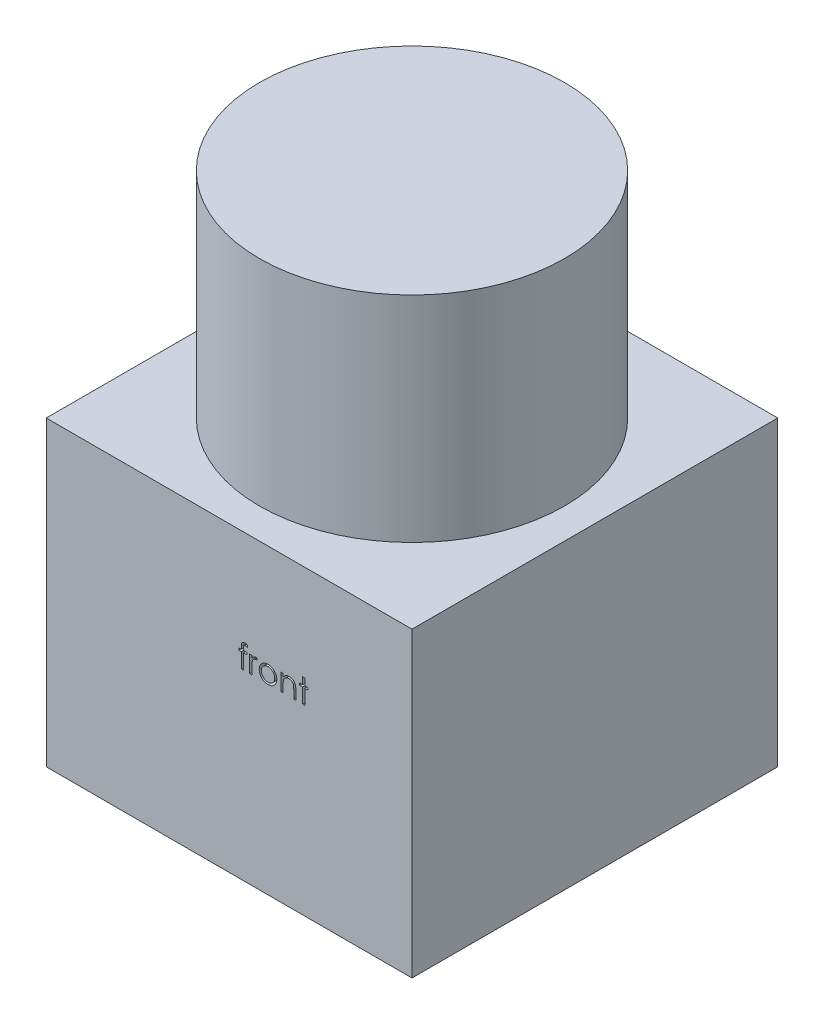
from build123d import *

# Parameters (mm, degrees)
SKETCH1_W           = 50
SKETCH1_H           = 41.3
BOSS_EXTRUDE1_DEPTH = 50
SKETCH2_R           = 20.85
BOSS_EXTRUDE2_DEPTH = 29.3
SKETCH3_R           = 1.7
CUT_EXTRUDE1_DEPTH  = 12.7
CUT_EXTRUDE2_DEPTH  = 2.54


with BuildPart() as part:
    # Sketch1 → Boss-Extrude1 (new body)
    with BuildSketch(Plane.XY):
        with Locations((25, 20.65)):
            Rectangle(SKETCH1_W, SKETCH1_H)
    extrude(amount=BOSS_EXTRUDE1_DEPTH)

    # Sketch2 → Boss-Extrude2 (add)
    with BuildSketch(Plane(origin=(0, 41.3, 0), x_dir=(1, 0, 0), z_dir=(0, 1, 0))):
        with Locations((25, -25)):
            Circle(SKETCH2_R)
    extrude(amount=BOSS_EXTRUDE2_DEPTH)

    # Sketch3 → Cut-Extrude1 (cut)
    with BuildSketch(Plane.XZ):
        with Locations((45.86404504, 45.86404504)):
            Circle(SKETCH3_R)
        with Locations((4.13595496, 4.13595496)):
            Circle(SKETCH3_R)
    extrude(amount=-CUT_EXTRUDE1_DEPTH, mode=Mode.SUBTRACT)

    # Sketch4 → Cut-Extrude2 (cut)
    with BuildSketch(Plane.XY.offset(50)):
        with BuildLine():
            Line((27.486215918, 28.180376343), (27.486215918, 27.883992128))
            add(Edge.make_bspline(
                [(27.486215918, 27.883992128), (27.459238597, 27.894833276), (27.408035081, 27.915410001), (27.332524168, 27.93778434), (27.263101583, 27.952240333), (27.218511983, 27.954268654), (27.197463915, 27.955226102)],
                knots=[0, 0, 0, 0, 8.7172e-05, 0.000165453, 0.000236054, 0.000299177, 0.000299177, 0.000299177, 0.000299177], degree=3))
            add(Edge.make_bspline(
                [(27.197463915, 27.955226102), (27.183245572, 27.954635244), (27.155723602, 27.953491539), (27.116169156, 27.947660174), (27.08052823, 27.935774062), (27.048863845, 27.920326075), (27.022601642, 27.90095478), (27.000116996, 27.881491791), (26.983818787, 27.859552377), (26.974969656, 27.839123148), (26.969572155, 27.820208318), (26.967948253, 27.800836948), (26.96397051, 27.777047955), (26.962861249, 27.747870868), (26.960332708, 27.714213409), (26.960556447, 27.675363296), (26.958484602, 27.631931888), (26.958794767, 27.601179247), (26.958957304, 27.585063843)],
                knots=[0, 0, 0, 0, 4.2689e-05, 8.2632e-05, 0.000119438, 0.000154993, 0.00018782, 0.000217084, 0.000243925, 0.000268981, 0.000283485, 0.000302734, 0.000327111, 0.000355796, 0.000390193, 0.00042836, 0.000472263, 0.000520601, 0.000520601, 0.000520601, 0.000520601], degree=3))
            Line((26.958957304, 27.585063843), (26.958957304, 27.263238923))
            Line((26.958957304, 27.263238923), (27.44551079, 27.263238923))
            Line((27.44551079, 27.263238923), (27.44551079, 26.978303025))
            Line((27.44551079, 26.978303025), (26.958321287, 26.978303025))
            Line((26.958321287, 26.978303025), (26.957049251, 24.943046615))
            Line((26.957049251, 24.943046615), (26.672113354, 24.943046615))
            Line((26.672113354, 24.943046615), (26.672113354, 26.978303025))
            Line((26.672113354, 26.978303025), (26.346472328, 26.978303025))
            Line((26.346472328, 26.978303025), (26.346472328, 27.263238923))
            Line((26.346472328, 27.263238923), (26.672113354, 27.263238923))
            Line((26.672113354, 27.263238923), (26.672113354, 27.6340372))
            add(Edge.make_bspline(
                [(26.672113354, 27.6340372), (26.672136227, 27.65460719), (26.672180107, 27.694068725), (26.675253371, 27.750864431), (26.677880203, 27.803318574), (26.683112266, 27.851023977), (26.689155385, 27.894427264), (26.697806044, 27.932883663), (26.705980645, 27.967429259), (26.720811153, 28.006529526), (26.742965595, 28.050843477), (26.77882513, 28.097673728), (26.821817359, 28.139678931), (26.873169195, 28.175064172), (26.930968288, 28.204469641), (26.995267642, 28.225553322), (27.065367286, 28.237473583), (27.113888062, 28.23924633), (27.138950293, 28.240162)],
                knots=[0, 0, 0, 0, 6.1697e-05, 0.00011836, 0.00017061, 0.000219214, 0.0002623, 0.000301968, 0.000337448, 0.000368639, 0.000427236, 0.000485368, 0.000544739, 0.000606848, 0.0006717, 0.000738675, 0.000809047, 0.000884229, 0.000884229, 0.000884229, 0.000884229], degree=3))
            add(Edge.make_bspline(
                [(27.138950293, 28.240162), (27.164419924, 28.239293519), (27.217892062, 28.237470189), (27.301527551, 28.226191312), (27.391875821, 28.206714021), (27.453866263, 28.189407654), (27.486215918, 28.180376343)],
                knots=[0, 0, 0, 0, 7.6417e-05, 0.000160434, 0.000252742, 0.000353487, 0.000353487, 0.000353487, 0.000353487], degree=3))
        make_face()
        with BuildLine():
            Line((27.811856944, 27.263238923), (28.096792841, 27.263238923))
            Line((28.096792841, 27.263238923), (28.096792841, 26.921697456))
            add(Edge.make_bspline(
                [(28.096792841, 26.921697456), (28.117828358, 26.953498101), (28.15805862, 27.014316586), (28.224926778, 27.094752309), (28.293419085, 27.161350244), (28.363863434, 27.214421293), (28.436777853, 27.254166051), (28.510562088, 27.283279018), (28.586376978, 27.300494154), (28.637323867, 27.302792545), (28.66284853, 27.303944051)],
                knots=[0, 0, 0, 0, 0.000114321, 0.000218637, 0.000313098, 0.00040036, 0.000482337, 0.000561472, 0.000637702, 0.000714238, 0.000714238, 0.000714238, 0.000714238], degree=3))
            add(Edge.make_bspline(
                [(28.66284853, 27.303944051), (28.682648126, 27.302864073), (28.723387082, 27.300641949), (28.785057003, 27.285029272), (28.84859642, 27.26010278), (28.889547014, 27.236662007), (28.910895405, 27.224441847)],
                knots=[0, 0, 0, 0, 5.9368e-05, 0.000122154, 0.000189829, 0.000263533, 0.000263533, 0.000263533, 0.000263533], degree=3))
            Line((28.910895405, 27.224441847), (28.754435069, 26.977667008))
            add(Edge.make_bspline(
                [(28.754435069, 26.977667008), (28.740729028, 26.983781392), (28.714712339, 26.995387664), (28.676653554, 27.00912363), (28.641564056, 27.01721164), (28.619208828, 27.018436933), (28.608787032, 27.019008154)],
                knots=[0, 0, 0, 0, 4.5014e-05, 8.5445e-05, 0.000121249, 0.000152517, 0.000152517, 0.000152517, 0.000152517], degree=3))
            add(Edge.make_bspline(
                [(28.608787032, 27.019008154), (28.585921831, 27.01748412), (28.539283448, 27.014375532), (28.470808224, 26.989938185), (28.404362545, 26.950454575), (28.351592537, 26.90666578), (28.310732779, 26.864440278), (28.281577003, 26.82756637), (28.254831939, 26.78622004), (28.229277525, 26.741108113), (28.20599453, 26.691460324), (28.184264223, 26.637772694), (28.16461654, 26.579983042), (28.153413104, 26.539721756), (28.147674251, 26.519098298)],
                knots=[0, 0, 0, 0, 6.8481e-05, 0.00013968, 0.000215495, 0.000299536, 0.000344518, 0.0003916, 0.000440288, 0.000492119, 0.000547026, 0.000604662, 0.000665806, 0.000730019, 0.000730019, 0.000730019, 0.000730019], degree=3))
            add(Edge.make_bspline(
                [(28.147674251, 26.519098298), (28.143381294, 26.500704005), (28.133872721, 26.459962043), (28.124627541, 26.391610167), (28.115493049, 26.310852991), (28.109055403, 26.217465724), (28.103088179, 26.111681579), (28.099722604, 25.9933394), (28.096907612, 25.862317717), (28.096832259, 25.770719553), (28.096792841, 25.722804227)],
                knots=[0, 0, 0, 0, 5.6638e-05, 0.000125448, 0.000206712, 0.000300468, 0.000406202, 0.000524563, 0.000655607, 0.000799348, 0.000799348, 0.000799348, 0.000799348], degree=3))
            Line((28.096792841, 25.722804227), (28.096792841, 24.943046615))
            Line((28.096792841, 24.943046615), (27.811856944, 24.943046615))
            Line((27.811856944, 24.943046615), (27.811856944, 27.263238923))
        make_face()
        with BuildLine():
            add(Edge.make_bspline(
                [(30.316494363, 27.303944051), (30.360029304, 27.30301705), (30.445390683, 27.301199427), (30.570402122, 27.281772994), (30.689732352, 27.252066456), (30.803838398, 27.210998682), (30.911258895, 27.155951484), (31.013558523, 27.090265913), (31.11045681, 27.012448846), (31.168534844, 26.952252598), (31.198014796, 26.921697456)],
                knots=[0, 0, 0, 0, 0.000130509, 0.000255897, 0.000378531, 0.000499054, 0.000618803, 0.000739829, 0.000863296, 0.000990571, 0.000990571, 0.000990571, 0.000990571], degree=3))
            add(Edge.make_bspline(
                [(31.198014796, 26.921697456), (31.223398426, 26.892474769), (31.273674442, 26.834594935), (31.338141201, 26.740745914), (31.393677902, 26.643554537), (31.438185017, 26.541730177), (31.47327786, 26.436161725), (31.49819317, 26.326486329), (31.513013104, 26.2129462), (31.51501151, 26.135835575), (31.51602361, 26.096782593)],
                knots=[0, 0, 0, 0, 0.000116043, 0.000229841, 0.000340916, 0.00045141, 0.000562633, 0.000674184, 0.000788337, 0.000905475, 0.000905475, 0.000905475, 0.000905475], degree=3))
            add(Edge.make_bspline(
                [(31.51602361, 26.096782593), (31.515133397, 26.057503255), (31.513374294, 25.979885451), (31.496734014, 25.865567883), (31.470852243, 25.754719723), (31.433811933, 25.64780505), (31.386315648, 25.544497057), (31.328357667, 25.445246966), (31.259531272, 25.349858959), (31.18151336, 25.259143006), (31.09528773, 25.175535083), (31.001746652, 25.102665867), (30.90272835, 25.040234912), (30.796916165, 24.989946164), (30.685276374, 24.950295222), (30.567568176, 24.922445921), (30.443974434, 24.905607822), (30.359585455, 24.903445581), (30.316494363, 24.902341487)],
                knots=[0, 0, 0, 0, 0.000117773, 0.000232725, 0.000345804, 0.000458844, 0.000571541, 0.000686407, 0.000803078, 0.000923941, 0.00104494, 0.001162753, 0.001279048, 0.001395399, 0.001513481, 0.001633808, 0.001757668, 0.001886907, 0.001886907, 0.001886907, 0.001886907], degree=3))
            add(Edge.make_bspline(
                [(30.316494363, 24.902341487), (30.273192154, 24.903449286), (30.188382588, 24.905618967), (30.06435259, 24.922380502), (29.946433436, 24.950282387), (29.834647493, 24.990076469), (29.728380382, 25.04023652), (29.628788345, 25.102477124), (29.535171279, 25.175556693), (29.448927407, 25.25913715), (29.370914387, 25.349860468), (29.302086729, 25.445246574), (29.244129076, 25.544497159), (29.196632706, 25.647805023), (29.159592418, 25.75471973), (29.133710641, 25.865567881), (29.117070362, 25.979885451), (29.115311259, 26.057503255), (29.114421046, 26.096782593)],
                knots=[0, 0, 0, 0, 0.000129874, 0.000254364, 0.000374691, 0.000492773, 0.000609698, 0.000726534, 0.000844346, 0.000965345, 0.001086209, 0.001202879, 0.001317745, 0.001430442, 0.001543482, 0.001656561, 0.001771513, 0.001889286, 0.001889286, 0.001889286, 0.001889286], degree=3))
            add(Edge.make_bspline(
                [(29.114421046, 26.096782593), (29.115440049, 26.135623316), (29.1174575, 26.212521274), (29.132262533, 26.325847965), (29.157080652, 26.435337739), (29.192215562, 26.540498707), (29.237132914, 26.641876852), (29.291889225, 26.739308378), (29.357013584, 26.832733025), (29.40708964, 26.890538055), (29.43242986, 26.919789404)],
                knots=[0, 0, 0, 0, 0.000116502, 0.000230655, 0.000342206, 0.000452826, 0.000562738, 0.000674367, 0.000787643, 0.000903686, 0.000903686, 0.000903686, 0.000903686], degree=3))
            add(Edge.make_bspline(
                [(29.43242986, 26.919789404), (29.461865368, 26.950609527), (29.519755473, 27.011222723), (29.617136105, 27.088812941), (29.719184071, 27.15586538), (29.827791682, 27.209818804), (29.941803989, 27.25230803), (30.061745731, 27.281849605), (30.187181377, 27.301129434), (30.272960462, 27.302996495), (30.316494363, 27.303944051)],
                knots=[0, 0, 0, 0, 0.000127724, 0.000251192, 0.000372563, 0.000493448, 0.000614191, 0.000736825, 0.000863471, 0.00099398, 0.00099398, 0.00099398, 0.00099398], degree=3))
        make_face()
        with BuildLine():
            add(Edge.make_bspline(
                [(30.315222328, 27.019008154), (30.284436067, 27.018133131), (30.223658286, 27.016405675), (30.134196234, 27.003266704), (30.048071951, 26.98245004), (29.965122043, 26.952873503), (29.885626236, 26.914683787), (29.809508421, 26.867776918), (29.736544708, 26.812774164), (29.668162407, 26.749761598), (29.605404167, 26.68092851), (29.550542003, 26.607587499), (29.503892085, 26.53092817), (29.465029941, 26.450870808), (29.436085563, 26.366604118), (29.415064321, 26.279082402), (29.401937746, 26.188127346), (29.400226531, 26.126295565), (29.399356944, 26.09487454)],
                knots=[0, 0, 0, 0, 9.233e-05, 0.000182276, 0.000270667, 0.000357773, 0.00044596, 0.000534752, 0.000625576, 0.000719657, 0.000813309, 0.000904642, 0.000993977, 0.001082163, 0.001171069, 0.001260696, 0.001351902, 0.001446138, 0.001446138, 0.001446138, 0.001446138], degree=3))
            add(Edge.make_bspline(
                [(29.399356944, 26.09487454), (29.400814562, 26.054278058), (29.403707663, 25.973701633), (29.427234627, 25.855037257), (29.466592181, 25.741116577), (29.519739213, 25.632607427), (29.58632914, 25.532211861), (29.664785265, 25.442702728), (29.754265565, 25.365427028), (29.85370339, 25.301309404), (29.961067664, 25.250364483), (30.074693041, 25.214261126), (30.193202813, 25.190791805), (30.274193191, 25.18845911), (30.315222328, 25.187277384)],
                knots=[0, 0, 0, 0, 0.000121719, 0.000241589, 0.000361264, 0.000482436, 0.000603094, 0.00072162, 0.000838414, 0.000956612, 0.001075534, 0.001193802, 0.001313553, 0.001436504, 0.001436504, 0.001436504, 0.001436504], degree=3))
            add(Edge.make_bspline(
                [(30.315222328, 25.187277384), (30.356249106, 25.188465996), (30.437234825, 25.190812282), (30.555579935, 25.214142925), (30.668894753, 25.250522675), (30.776147511, 25.301252108), (30.875540073, 25.365670513), (30.965663919, 25.442266369), (31.043450159, 25.532448934), (31.109974215, 25.632740407), (31.163991617, 25.740948355), (31.20316495, 25.855058283), (31.226748475, 25.973696278), (31.229633941, 26.054276264), (31.231087713, 26.09487454)],
                knots=[0, 0, 0, 0, 0.000122951, 0.000242701, 0.000360364, 0.000479286, 0.000597484, 0.00071476, 0.000832868, 0.000953525, 0.00107498, 0.001194654, 0.001314525, 0.001436243, 0.001436243, 0.001436243, 0.001436243], degree=3))
            add(Edge.make_bspline(
                [(31.231087713, 26.09487454), (31.230218425, 26.126295753), (31.228507799, 26.188127903), (31.215376939, 26.279080272), (31.194371556, 26.366611935), (31.165368732, 26.450841966), (31.126675448, 26.531135452), (31.079125929, 26.607362419), (31.024487784, 26.681182571), (30.960972253, 26.749539088), (30.892661332, 26.812798729), (30.819668047, 26.867798246), (30.743663102, 26.914477636), (30.664398245, 26.953200155), (30.581437702, 26.982180956), (30.495434092, 27.0033869), (30.406353743, 27.01635015), (30.345793753, 27.018116486), (30.315222328, 27.019008154)],
                knots=[0, 0, 0, 0, 9.4236e-05, 0.000185442, 0.000275068, 0.000363974, 0.000452161, 0.000541828, 0.00063316, 0.000727242, 0.000821323, 0.000912146, 0.001000939, 0.001088552, 0.001176258, 0.001264031, 0.001353977, 0.001445672, 0.001445672, 0.001445672, 0.001445672], degree=3))
        make_face(mode=Mode.SUBTRACT)
        with BuildLine():
            Line((32.085895405, 27.263238923), (32.370831303, 27.263238923))
            Line((32.370831303, 27.263238923), (32.370831303, 26.844739323))
            add(Edge.make_bspline(
                [(32.370831303, 26.844739323), (32.401254729, 26.882696651), (32.460292449, 26.956354168), (32.558612522, 27.053164975), (32.662520203, 27.132943858), (32.771379164, 27.196538014), (32.88533718, 27.244477453), (33.003699611, 27.279099405), (33.127175094, 27.299859214), (33.211144262, 27.30257178), (33.253623771, 27.303944051)],
                knots=[0, 0, 0, 0, 0.000145848, 0.000283023, 0.000412777, 0.000537898, 0.000660162, 0.000782735, 0.000907163, 0.001034558, 0.001034558, 0.001034558, 0.001034558], degree=3))
            add(Edge.make_bspline(
                [(33.253623771, 27.303944051), (33.296559417, 27.302360909), (33.380594834, 27.299262319), (33.502948504, 27.274754321), (33.617224369, 27.232893983), (33.723014966, 27.175551604), (33.818380366, 27.104244303), (33.902132196, 27.021170173), (33.97140457, 26.925615297), (34.017847892, 26.836966434), (34.048441873, 26.758327314), (34.067702636, 26.690974905), (34.084059312, 26.615937725), (34.098239541, 26.533442526), (34.107834492, 26.442911311), (34.115402142, 26.34471519), (34.120825672, 26.238885972), (34.121040853, 26.165691674), (34.121151815, 26.127947456)],
                knots=[0, 0, 0, 0, 0.000128741, 0.000251978, 0.000372501, 0.000492599, 0.000611662, 0.000728592, 0.000845121, 0.000964321, 0.001027748, 0.001097989, 0.001174219, 0.001258077, 0.001348963, 0.001447206, 0.001553543, 0.001666761, 0.001666761, 0.001666761, 0.001666761], degree=3))
            Line((34.121151815, 26.127947456), (34.121151815, 24.943046615))
            Line((34.121151815, 24.943046615), (33.836215918, 24.943046615))
            Line((33.836215918, 24.943046615), (33.836215918, 26.034452865))
            add(Edge.make_bspline(
                [(33.836215918, 26.034452865), (33.836040651, 26.066041797), (33.835705394, 26.126466048), (33.834647986, 26.212979377), (33.83209909, 26.291435058), (33.828517406, 26.361645527), (33.823275, 26.423543365), (33.817811613, 26.477254637), (33.811130527, 26.522711151), (33.805177027, 26.55007519), (33.802506984, 26.562347496)],
                knots=[0, 0, 0, 0, 9.4769e-05, 0.000181277, 0.000259548, 0.000330249, 0.000392152, 0.000445883, 0.000492208, 0.000529878, 0.000529878, 0.000529878, 0.000529878], degree=3))
            add(Edge.make_bspline(
                [(33.802506984, 26.562347496), (33.792868109, 26.598371214), (33.774316256, 26.667705725), (33.728474715, 26.761753174), (33.670586136, 26.84176153), (33.599921659, 26.907236127), (33.517163854, 26.958191101), (33.422542375, 26.993546045), (33.316970322, 27.015658804), (33.242716704, 27.017860559), (33.204014396, 27.019008154)],
                knots=[0, 0, 0, 0, 0.000111666, 0.000214922, 0.000311858, 0.000406371, 0.000502038, 0.000601493, 0.000708018, 0.000823984, 0.000823984, 0.000823984, 0.000823984], degree=3))
            add(Edge.make_bspline(
                [(33.204014396, 27.019008154), (33.181092997, 27.018576349), (33.135732141, 27.01772182), (33.068467524, 27.009148142), (33.003222024, 26.995125115), (32.939340834, 26.976194279), (32.878101621, 26.950193507), (32.817536871, 26.920684721), (32.759927164, 26.8839017), (32.704044082, 26.84290735), (32.652053178, 26.797478355), (32.603676757, 26.749540835), (32.560552981, 26.698490823), (32.52148354, 26.645150871), (32.487757544, 26.588788418), (32.458317957, 26.529947226), (32.433339148, 26.468549848), (32.420926992, 26.425936757), (32.414716519, 26.404615125)],
                knots=[0, 0, 0, 0, 6.8737e-05, 0.000136029, 0.000203016, 0.000268809, 0.000335543, 0.000402385, 0.000470679, 0.000540262, 0.000610145, 0.000677605, 0.000744384, 0.000810411, 0.000875747, 0.000941168, 0.001007661, 0.001074249, 0.001074249, 0.001074249, 0.001074249], degree=3))
            add(Edge.make_bspline(
                [(32.414716519, 26.404615125), (32.411142695, 26.38896219), (32.403362667, 26.354886572), (32.394959639, 26.298966277), (32.387332767, 26.234277942), (32.380949241, 26.160897055), (32.377043613, 26.078566697), (32.372785124, 25.987638472), (32.371234762, 25.887749808), (32.370969555, 25.818206701), (32.370831303, 25.781953867)],
                knots=[0, 0, 0, 0, 4.8153e-05, 0.000104826, 0.000169516, 0.000243568, 0.000325735, 0.000416765, 0.000516638, 0.000625399, 0.000625399, 0.000625399, 0.000625399], degree=3))
            Line((32.370831303, 25.781953867), (32.370831303, 24.943046615))
            Line((32.370831303, 24.943046615), (32.085895405, 24.943046615))
            Line((32.085895405, 24.943046615), (32.085895405, 27.263238923))
        make_face()
        Polygon((35.057369764, 28.199456871), (35.342305662, 28.199456871), (35.342305662, 27.263238923), (35.749356944, 27.263238923), (35.749356944, 26.978303025), (35.342305662, 26.978303025), (35.342305662, 24.943046615), (35.057369764, 24.943046615), (35.057369764, 26.978303025), (34.650318482, 26.978303025), (34.650318482, 27.263238923), (35.057369764, 27.263238923), align=None)
    extrude(amount=-CUT_EXTRUDE2_DEPTH, mode=Mode.SUBTRACT)


solid = part.part
